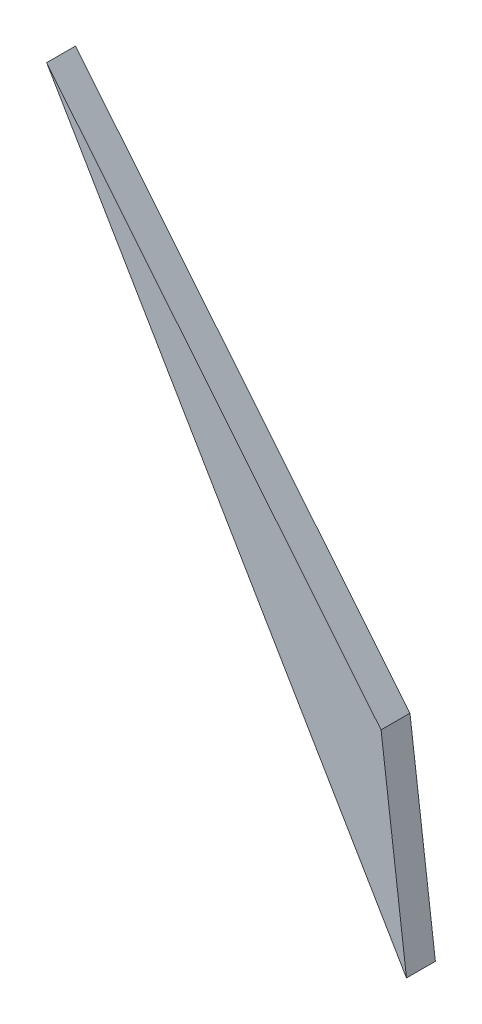
from build123d import *

# Parameters (mm, degrees)
BOSS_EXTRU_1_DEPTH = 3


with BuildPart() as part:
    # Esquisse1 → Boss.-Extru.1 (new body)
    with BuildSketch(Plane.XY):
        Polygon((-2.86929474, -1.227661982), (-37.604296747, 41.415973364), (-0.229693264, -22.227661982), align=None)
    extrude(amount=BOSS_EXTRU_1_DEPTH)


solid = part.part
